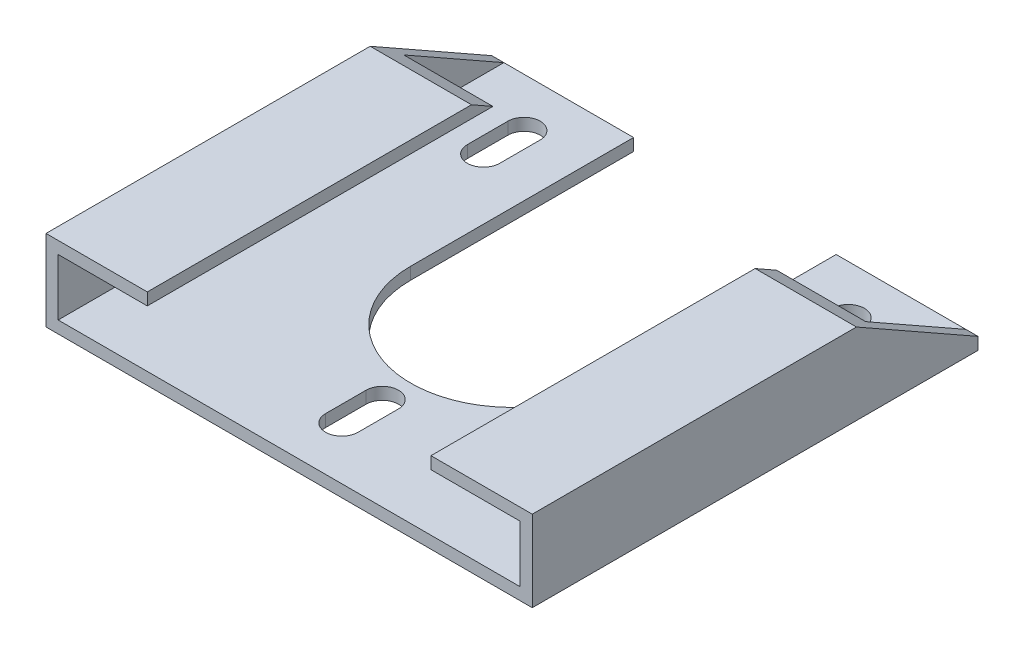
from build123d import *

# Parameters (mm, degrees)
BOSS_EXTRUDE1_DEPTH = 3
SKETCH1_3_W         = 3
SKETCH1_3_H         = 110
BOSS_EXTRUDE2_DEPTH = 20
SKETCH4_W           = 110
SKETCH4_H           = 3
BOSS_EXTRUDE3_DEPTH = 22
SKETCH9_W           = 153.774265812
SKETCH9_H           = 63.565026257
CUT_EXTRUDE1_DEPTH  = 96.502301832
CUT_EXTRUDE2_DEPTH  = 22
CUT_EXTRUDE3_DEPTH  = 22


with BuildPart() as part:
    # Sketch1 → Boss-Extrude1 (new body)
    with BuildSketch(Plane(origin=(0, 0, 0), x_dir=(1, 0, 0), z_dir=(0, 1, 0))):
        with BuildLine():
            Line((-25, 55), (-57, 55))
            Line((-57, 55), (-57, -55))
            Line((-57, -55), (57, -55))
            Line((57, -55), (57, 55))
            Line((57, 55), (25, 55))
            Line((25, 55), (25, 0))
            ThreePointArc((25, 0), (0, -25), (-25, 0))
            Line((-25, 0), (-25, 55))
        make_face()
    extrude(amount=BOSS_EXTRUDE1_DEPTH)

    # Sketch1_3 → Boss-Extrude2 (add)
    with BuildSketch(Plane(origin=(0, 0, 0), x_dir=(1, 0, 0), z_dir=(0, 1, 0))):
        with Locations((-58.5, 0)):
            Rectangle(SKETCH1_3_W, SKETCH1_3_H)
        with Locations((58.5, 0)):
            Rectangle(SKETCH1_3_W, SKETCH1_3_H)
    extrude(amount=BOSS_EXTRUDE2_DEPTH)

    # Sketch4 → Boss-Extrude3 (add)
    with BuildSketch(Plane(origin=(-57, 0, 0), x_dir=(0, 0, -1), z_dir=(1, 0, 0))):
        with Locations((0, 18.5)):
            Rectangle(SKETCH4_W, SKETCH4_H)
    boss_extrude3 = extrude(amount=BOSS_EXTRUDE3_DEPTH)

    # Mirror1: Boss-Extrude3 across plane
    add(boss_extrude3.mirror(Plane(origin=(0, 0, 0), x_dir=(0, 0, 1), z_dir=(1, 0, 0))))

    # Sketch9 → Cut-Extrude1 (cut, through all)
    with BuildSketch(Plane(origin=(0, 25.862068966, -14.655172414), x_dir=(1, 0, 0), z_dir=(0, 0.8700221858486125, -0.4930125719808804))):
        with Locations((-2.934476774, 31.782513129)):
            Rectangle(SKETCH9_W, SKETCH9_H)
    extrude(amount=CUT_EXTRUDE1_DEPTH, mode=Mode.SUBTRACT)

    # Sketch10 → Cut-Extrude2 (cut)
    with BuildSketch(Plane(origin=(0, 3, 0), x_dir=(1, 0, 0), z_dir=(0, 1, 0))):
        with BuildLine():
            Line((-36, 42.9741892), (-36, 32.9741892))
            ThreePointArc((-36, 32.9741892), (-40, 28.9741892), (-44, 32.9741892))
            Line((-44, 32.9741892), (-44, 42.9741892))
            ThreePointArc((-44, 42.9741892), (-40, 46.9741892), (-36, 42.9741892))
        make_face()
    cut_extrude2 = extrude(amount=-CUT_EXTRUDE2_DEPTH, mode=Mode.SUBTRACT)

    # Mirror2: Cut-Extrude2 across plane
    add(cut_extrude2.mirror(Plane(origin=(0, 0, 0), x_dir=(0, 0, 1), z_dir=(1, 0, 0))), mode=Mode.SUBTRACT)

    # Sketch11 → Cut-Extrude3 (cut)
    with BuildSketch(Plane(origin=(0, 3, 0), x_dir=(1, 0, 0), z_dir=(0, 1, 0))):
        with BuildLine():
            Line((4, -32), (4, -42))
            ThreePointArc((4, -42), (0, -46), (-4, -42))
            Line((-4, -42), (-4, -32))
            ThreePointArc((-4, -32), (0, -28), (4, -32))
        make_face()
    extrude(amount=-CUT_EXTRUDE3_DEPTH, mode=Mode.SUBTRACT)


solid = part.part
